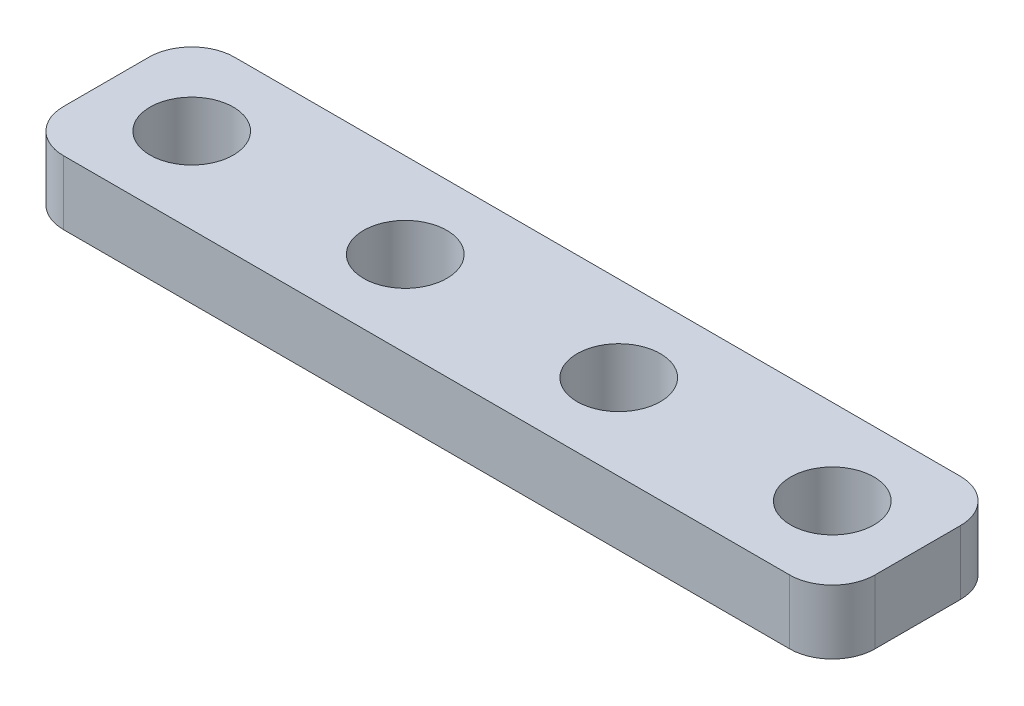
from build123d import *

# Parameters (mm, degrees)
BOSS_EXTRUDE1_DEPTH = 3
SKETCH2_R           = 1.95
CUT_EXTRUDE1_DEPTH  = 4


with BuildPart() as part:
    # Sketch1 → Boss-Extrude1 (new body)
    with BuildSketch(Plane(origin=(0, 0, 0), x_dir=(1, 0, 0), z_dir=(0, 1, 0))):
        with BuildLine():
            Line((2, 0), (36, 0))
            ThreePointArc((36, 0), (37.414213562, -0.585786438), (38, -2))
            Line((38, -2), (38, -6))
            ThreePointArc((38, -6), (37.414213562, -7.414213562), (36, -8))
            Line((36, -8), (2, -8))
            ThreePointArc((2, -8), (0.585786438, -7.414213562), (0, -6))
            Line((0, -6), (0, -2))
            ThreePointArc((0, -2), (0.585786438, -0.585786438), (2, 0))
        make_face()
    extrude(amount=BOSS_EXTRUDE1_DEPTH)

    # Sketch2 → Cut-Extrude1 (cut, through all)
    with BuildSketch(Plane(origin=(0, 3, 0), x_dir=(1, 0, 0), z_dir=(0, 1, 0))):
        with Locations((34, -4)):
            Circle(SKETCH2_R)
        with Locations((24, -4)):
            Circle(SKETCH2_R)
        with Locations((14, -4)):
            Circle(SKETCH2_R)
        with Locations((-16, -4)):
            Circle(SKETCH2_R)
        with Locations((4, -4)):
            Circle(SKETCH2_R)
        with Locations((-6, -4)):
            Circle(SKETCH2_R)
    extrude(amount=-CUT_EXTRUDE1_DEPTH, mode=Mode.SUBTRACT)


solid = part.part
